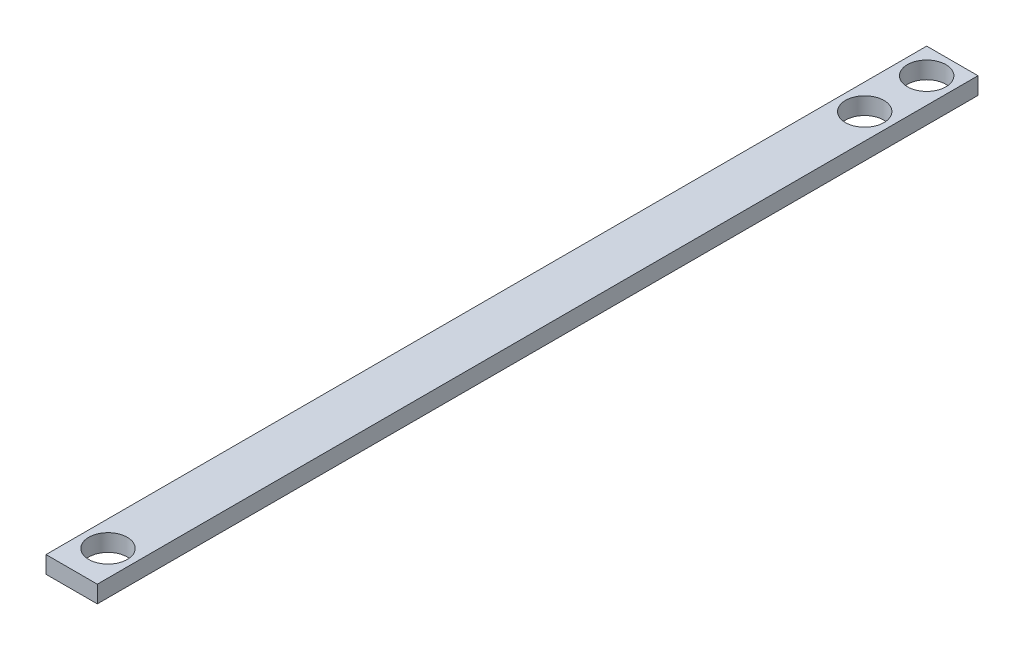
from build123d import *

# Parameters (mm, degrees)
SKETCH1_W           = 38.1
SKETCH1_H           = 12.7
BOSS_EXTRUDE1_DEPTH = 615.95
SKETCH2_R           = 14.3002
CUT_EXTRUDE1_DEPTH  = 762
SKETCH3_W           = 38.1
SKETCH3_H           = 12.7
BOSS_EXTRUDE2_DEPTH = 38.1
SKETCH4_R           = 14.3002
CUT_EXTRUDE2_DEPTH  = 101.6


with BuildPart() as part:
    # Sketch1 → Boss-Extrude1 (new body)
    with BuildSketch(Plane.XY):
        with Locations((19.05, 6.35)):
            Rectangle(SKETCH1_W, SKETCH1_H)
    extrude(amount=BOSS_EXTRUDE1_DEPTH)

    # Sketch2 → Cut-Extrude1 (cut)
    with BuildSketch(Plane(origin=(0, 12.7, 0), x_dir=(1, 0, 0), z_dir=(0, 1, 0))):
        with Locations((19.05, -588.9498)):
            Circle(SKETCH2_R)
        with Locations((19.05, -27.0002)):
            Circle(SKETCH2_R)
    extrude(amount=-CUT_EXTRUDE1_DEPTH, mode=Mode.SUBTRACT)

    # Sketch3 → Boss-Extrude2 (add)
    with BuildSketch(Plane(origin=(0, 0, 0), x_dir=(-1, 0, 0), z_dir=(0, 0, -1))):
        with Locations((-19.05, 6.35)):
            Rectangle(SKETCH3_W, SKETCH3_H)
    extrude(amount=BOSS_EXTRUDE2_DEPTH)

    # Sketch4 → Cut-Extrude2 (cut)
    with BuildSketch(Plane(origin=(0, 12.7, 0), x_dir=(1, 0, 0), z_dir=(0, 1, 0))):
        with Locations((19.05, 19.0373)):
            Circle(SKETCH4_R)
    extrude(amount=-CUT_EXTRUDE2_DEPTH, mode=Mode.SUBTRACT)


solid = part.part
